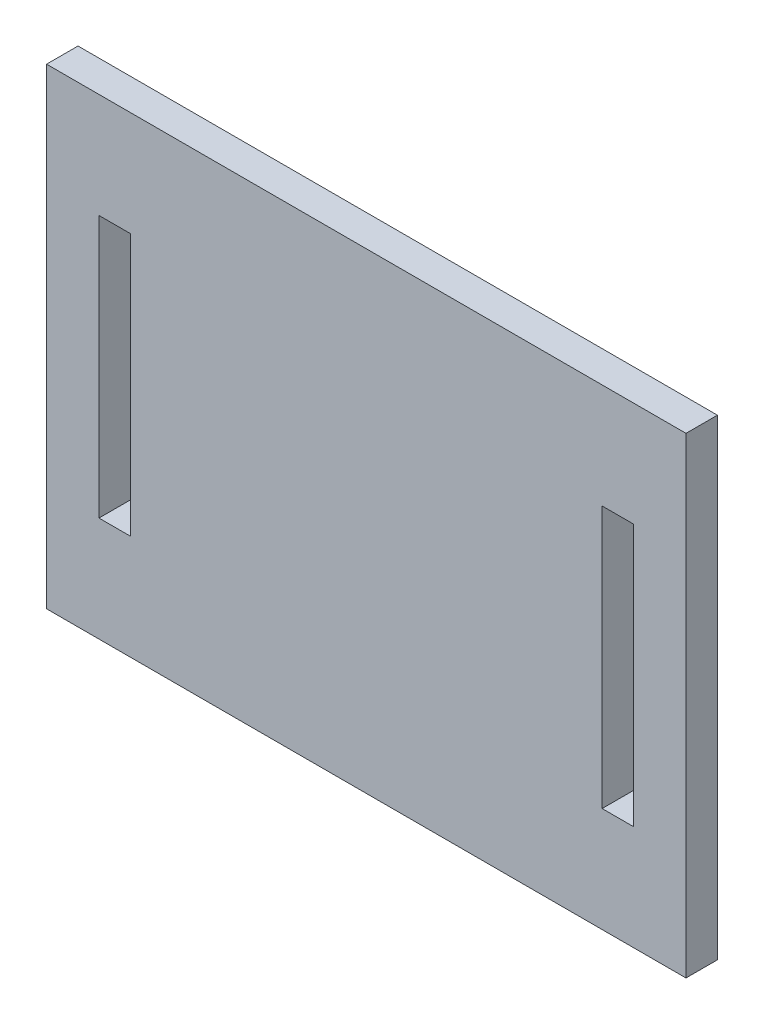
from build123d import *

# Parameters (mm, degrees)
ESBO_O1_W                = 61
ESBO_O1_H                = 45
RESSALTO_EXTRUS_O1_DEPTH = 3
ESBO_O3_W                = 3
ESBO_O3_H                = 25
CORTE_EXTRUS_O1_DEPTH    = 3


with BuildPart() as part:
    # Esboço1 → Ressalto-extrusão1 (new body)
    with BuildSketch(Plane.XY):
        with Locations((-2.821546011, -7.708333333)):
            Rectangle(ESBO_O1_W, ESBO_O1_H)
    extrude(amount=RESSALTO_EXTRUS_O1_DEPTH)

    # Esboço3 → Corte-extrusão1 (cut)
    with BuildSketch(Plane.XY.offset(3)):
        with Locations((-26.821546011, -7.708333333)):
            Rectangle(ESBO_O3_W, ESBO_O3_H)
        with Locations((21.178453989, -7.708333333)):
            Rectangle(ESBO_O3_W, ESBO_O3_H)
    extrude(amount=-CORTE_EXTRUS_O1_DEPTH, mode=Mode.SUBTRACT)


solid = part.part
